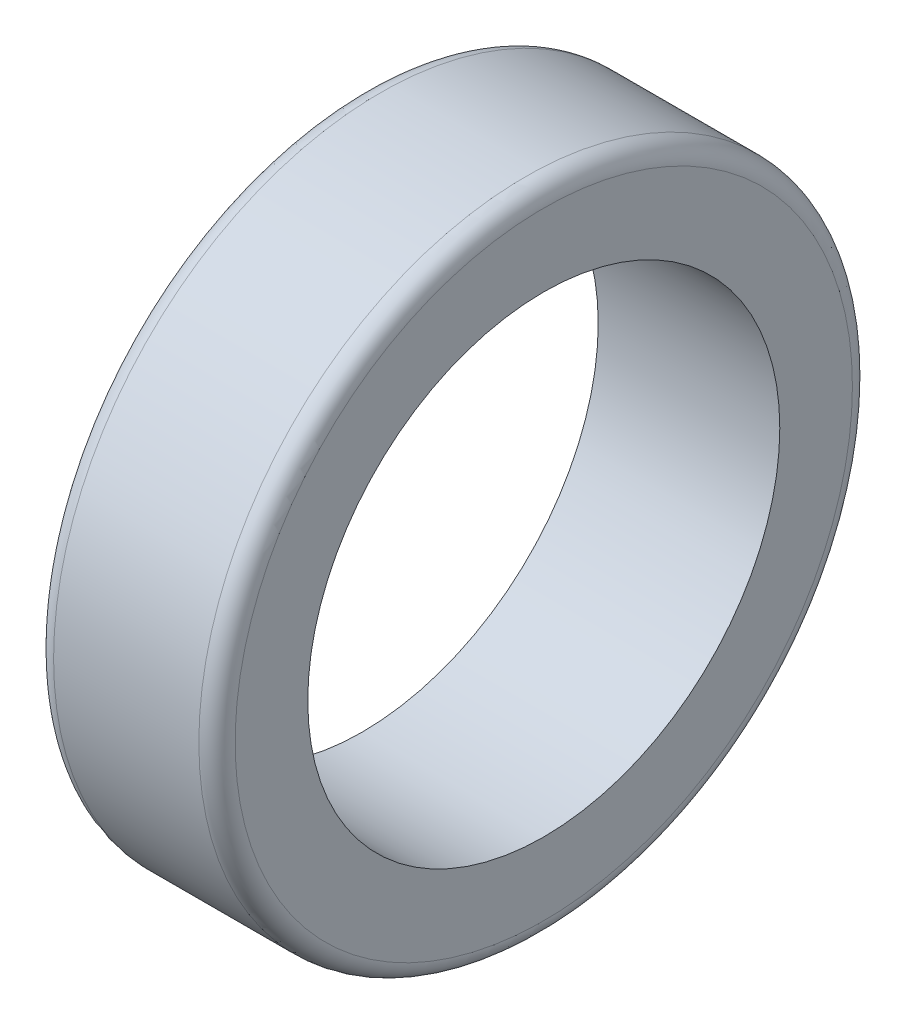
from build123d import *

# Parameters (mm, degrees)
SKETCH2_R      = 65
EXTRUDE1_DEPTH = 51


with BuildPart() as part:
    # Sketch1 → Revolve1 (revolve)
    with BuildSketch(Plane.XY):
        with BuildLine():
            Line((25, -45), (-25, -45))
            Line((-25, -45), (-25, 40))
            ThreePointArc((-25, 40), (-23.535533906, 43.535533906), (-20, 45))
            Line((-20, 45), (20, 45))
            ThreePointArc((20, 45), (23.535533906, 43.535533906), (25, 40))
            Line((25, 40), (25, -45))
        make_face()
    revolve(axis=Axis((25, -45, 0), (-1, 0, 0)))

    # Sketch2 → Extrude1 (cut, through all)
    with BuildSketch(Plane(origin=(25, 0, 0), x_dir=(0, 0, -1), z_dir=(1, 0, 0))):
        with Locations((0, -45)):
            Circle(SKETCH2_R)
    extrude(amount=-EXTRUDE1_DEPTH, mode=Mode.SUBTRACT)


solid = part.part
